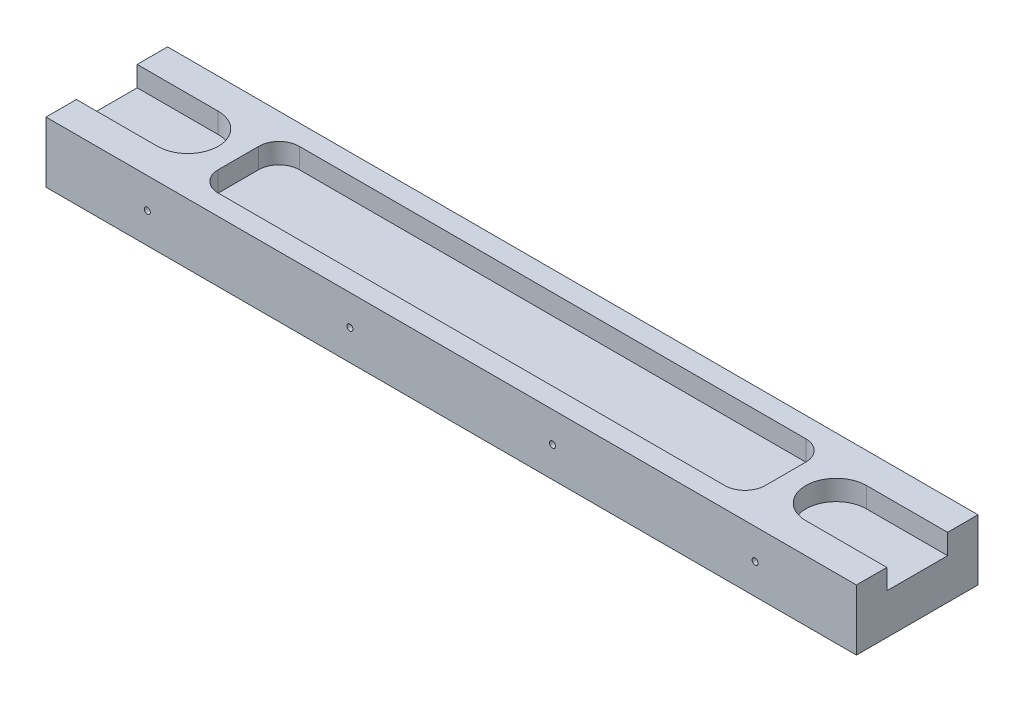
from build123d import *

# Parameters (mm, degrees)
SKETCH1_W           = 200
SKETCH1_H           = 30
BOSS_EXTRUDE1_DEPTH = 15
CUT_EXTRUDE1_DEPTH  = 5
SKETCH3_R           = 0.75
CUT_EXTRUDE2_DEPTH  = 30
CUT_EXTRUDE3_DEPTH  = 5


with BuildPart() as part:
    # Sketch1 → Boss-Extrude1 (new body)
    with BuildSketch(Plane(origin=(0, 0, 0), x_dir=(1, 0, 0), z_dir=(0, 1, 0))):
        with Locations((100, 15)):
            Rectangle(SKETCH1_W, SKETCH1_H)
    extrude(amount=BOSS_EXTRUDE1_DEPTH)

    # Sketch2 → Cut-Extrude1 (cut)
    with BuildSketch(Plane(origin=(0, 15, 0), x_dir=(1, 0, 0), z_dir=(0, 1, 0))):
        with BuildLine():
            Line((-20, 22.5), (20, 22.5))
            ThreePointArc((20, 22.5), (27.5, 15), (20, 7.5))
            Line((20, 7.5), (-20, 7.5))
            ThreePointArc((-20, 7.5), (-27.5, 15), (-20, 22.5))
        make_face()
        with BuildLine():
            Line((220, 22.5), (180, 22.5))
            ThreePointArc((180, 22.5), (172.5, 15), (180, 7.5))
            Line((180, 7.5), (220, 7.5))
            ThreePointArc((220, 7.5), (227.5, 15), (220, 22.5))
        make_face()
    extrude(amount=-CUT_EXTRUDE1_DEPTH, mode=Mode.SUBTRACT)

    # Sketch3 → Cut-Extrude2 (cut)
    with BuildSketch(Plane.XY):
        with Locations((25, 7.5)):
            Circle(SKETCH3_R)
        with Locations((75, 7.5)):
            Circle(SKETCH3_R)
        with Locations((125, 7.5)):
            Circle(SKETCH3_R)
        with Locations((175, 7.5)):
            Circle(SKETCH3_R)
    extrude(amount=-CUT_EXTRUDE2_DEPTH, mode=Mode.SUBTRACT)

    # Sketch4 → Cut-Extrude3 (cut)
    with BuildSketch(Plane(origin=(0, 15, 0), x_dir=(1, 0, 0), z_dir=(0, 1, 0))):
        with BuildLine():
            Line((37.5, 25), (162.5, 25))
            ThreePointArc((162.5, 25), (166.035533906, 23.535533906), (167.5, 20))
            Line((167.5, 20), (167.5, 10))
            ThreePointArc((167.5, 10), (166.035533906, 6.464466094), (162.5, 5))
            Line((162.5, 5), (37.5, 5))
            ThreePointArc((37.5, 5), (33.964466094, 6.464466094), (32.5, 10))
            Line((32.5, 10), (32.5, 20))
            ThreePointArc((32.5, 20), (33.964466094, 23.535533906), (37.5, 25))
        make_face()
    extrude(amount=-CUT_EXTRUDE3_DEPTH, mode=Mode.SUBTRACT)


solid = part.part
